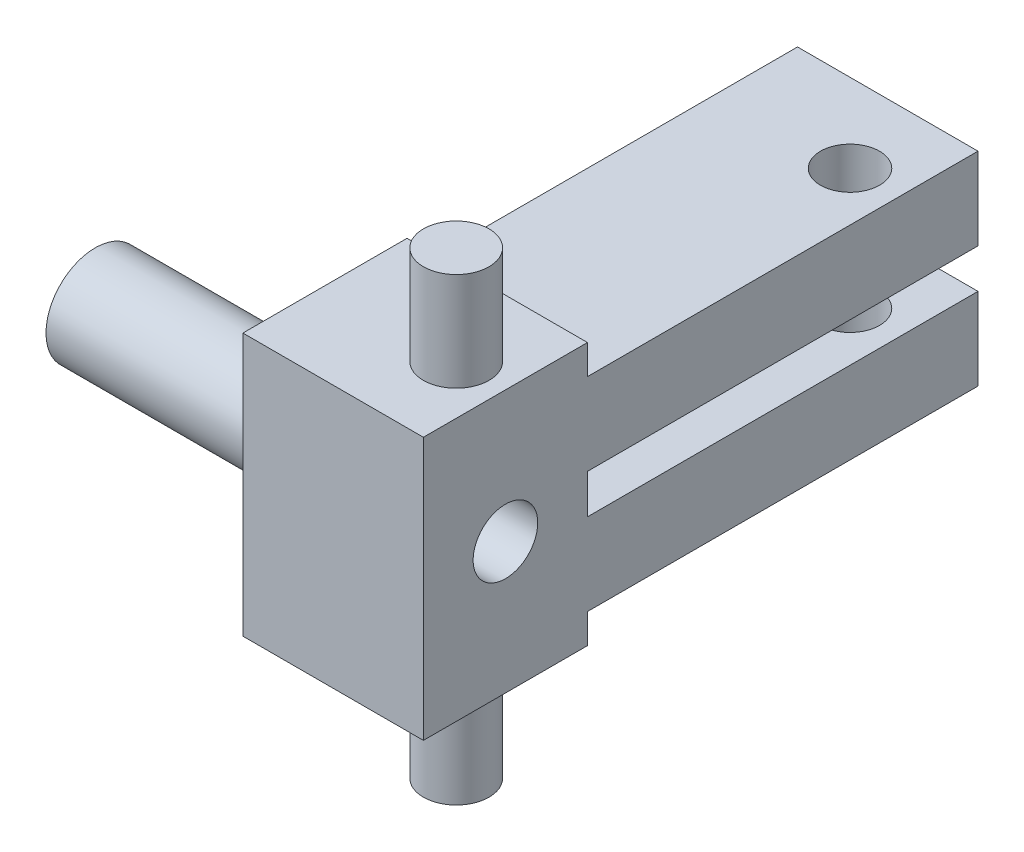
from build123d import *

# Parameters (mm, degrees)
SKETCH1_W           = 13.97
SKETCH1_H           = 12.7
BOSS_EXTRUDE1_DEPTH = 10.16
SKETCH1_3_R         = 2.54
BOSS_EXTRUDE2_DEPTH = 17.78
BOSS_EXTRUDE3_START = 53.34
SKETCH2_R           = 3.81
BOSS_EXTRUDE3_DEPTH = 31.75
BOSS_EXTRUDE4_START = 53.34
SKETCH3_W           = 30.48
SKETCH3_H           = 6.35
BOSS_EXTRUDE4_DEPTH = 13.97
CUT_EXTRUDE1_START  = -1
SKETCH4_R           = 2.5
CUT_EXTRUDE1_DEPTH  = 87.09
SKETCH6_R           = 2.286
CUT_EXTRUDE3_DEPTH  = 18.78
SKETCH5_W           = 115.291364872
SKETCH5_H           = 73.621660508
CUT_EXTRUDE2_DEPTH  = 32.75


with BuildPart() as part:
    # Sketch1 → Boss-Extrude1 (new body, symmetric)
    with BuildSketch(Plane(origin=(0, 0, 0), x_dir=(1, 0, 0), z_dir=(0, 1, 0))):
        with Locations((60.325, 0)):
            Rectangle(SKETCH1_W, SKETCH1_H)
    boss_extrude1 = extrude(amount=BOSS_EXTRUDE1_DEPTH, both=True)

    # Sketch1_3 → Boss-Extrude2 (add, symmetric)
    with BuildSketch(Plane(origin=(0, 0, 0), x_dir=(1, 0, 0), z_dir=(0, 1, 0))):
        with Locations((57.15, 0)):
            Circle(SKETCH1_3_R)
    boss_extrude2 = extrude(amount=BOSS_EXTRUDE2_DEPTH, both=True)

    # Sketch2 → Boss-Extrude3 (add)
    with BuildSketch(Plane(origin=(0, 0, 0), x_dir=(0, 0, -1), z_dir=(1, 0, 0)).offset(BOSS_EXTRUDE3_START)):
        Circle(SKETCH2_R)
    boss_extrude3 = extrude(amount=BOSS_EXTRUDE3_DEPTH)

    # Sketch3 → Boss-Extrude4 (add)
    with BuildSketch(Plane(origin=(0, 0, 0), x_dir=(0, 0, -1), z_dir=(1, 0, 0)).offset(BOSS_EXTRUDE4_START)):
        with Locations((21.336, 4.699)):
            Rectangle(SKETCH3_W, SKETCH3_H)
        with Locations((21.336, -4.699)):
            Rectangle(SKETCH3_W, SKETCH3_H)
    boss_extrude4 = extrude(amount=BOSS_EXTRUDE4_DEPTH)

    # Sketch4 → Cut-Extrude1 (cut)
    with BuildSketch(Plane(origin=(0, 0, 0), x_dir=(0, 0, -1), z_dir=(1, 0, 0)).offset(CUT_EXTRUDE1_START)):
        Circle(SKETCH4_R)
    cut_extrude1 = extrude(amount=CUT_EXTRUDE1_DEPTH, mode=Mode.SUBTRACT)

    # Sketch6 → Cut-Extrude3 (cut, symmetric)
    with BuildSketch(Plane(origin=(0, 0, 0), x_dir=(1, 0, 0), z_dir=(0, 1, 0))):
        with Locations((57.15, 30.48)):
            Circle(SKETCH6_R)
    cut_extrude3 = extrude(amount=CUT_EXTRUDE3_DEPTH, both=True, mode=Mode.SUBTRACT)

    # Mirror11: Boss-Extrude1, Boss-Extrude2, Boss-Extrude3, Boss-Extrude4, Cut-Extrude1, Cut-Extrude3 across plane
    add(boss_extrude1.mirror(Plane(origin=(53.34, 10.16, -6.35), x_dir=(0, 0, 1), z_dir=(1, 0, 0))))
    add(boss_extrude2.mirror(Plane(origin=(53.34, 10.16, -6.35), x_dir=(0, 0, 1), z_dir=(1, 0, 0))))
    add(boss_extrude3.mirror(Plane(origin=(53.34, 10.16, -6.35), x_dir=(0, 0, 1), z_dir=(1, 0, 0))))
    add(boss_extrude4.mirror(Plane(origin=(53.34, 10.16, -6.35), x_dir=(0, 0, 1), z_dir=(1, 0, 0))))
    add(cut_extrude1.mirror(Plane(origin=(53.34, 10.16, -6.35), x_dir=(0, 0, 1), z_dir=(1, 0, 0))), mode=Mode.SUBTRACT)
    add(cut_extrude3.mirror(Plane(origin=(53.34, 10.16, -6.35), x_dir=(0, 0, 1), z_dir=(1, 0, 0))), mode=Mode.SUBTRACT)

    # Sketch5 → Cut-Extrude2 (cut, through all)
    with BuildSketch(Plane(origin=(53.34, 0, 0), x_dir=(0, 0, -1), z_dir=(1, 0, 0))):
        with Locations((14.102354185, -2.798711487)):
            Rectangle(SKETCH5_W, SKETCH5_H)
    extrude(amount=CUT_EXTRUDE2_DEPTH, mode=Mode.SUBTRACT)


solid = part.part
